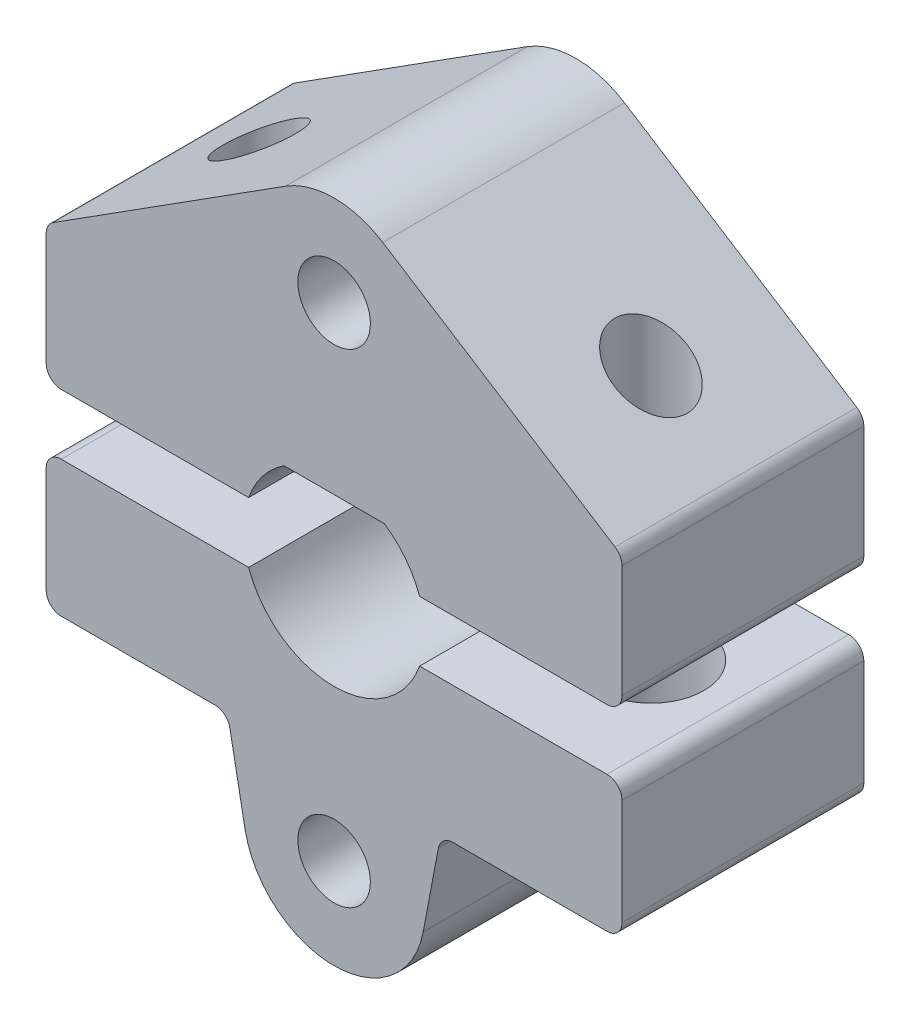
from build123d import *

# Parameters (mm, degrees)
SKETCH_1_R          = 1.2
EXTRUDE_1_DEPTH     = 8
EXTRUDE_1_2_DEPTH   = 8
SKETCH_2_R          = 1.2
CUT_EXTRUDE_1_DEPTH = 17.5
SKETCH_3_R          = 1.75
CUT_EXTRUDE_2_DEPTH = 4.5


with BuildPart() as part:
    # 草图1 → 凸台-拉伸1 (new body)
    with BuildSketch(Plane.XY):
        with BuildLine():
            Line((-1.658312395, 2.5), (1.658312395, 2.5))
            ThreePointArc((1.658312395, 2.5), (2.365419176, 1.84520788), (2.828427125, 1))
            Line((2.828427125, 1), (9.026279442, 1))
            ThreePointArc((9.026279442, 1), (9.379832832, 1.146446609), (9.526279442, 1.5))
            Line((9.526279442, 1.5), (9.526279442, 5.225344163))
            ThreePointArc((9.526279442, 5.225344163), (9.464514711, 5.466071912), (9.294480045, 5.647325722))
            Line((9.294480045, 5.647325722), (1.609203622, 10.531889354))
            ThreePointArc((1.609203622, 10.531889354), (0, 11), (-1.609203622, 10.531889354))
            Line((-1.609203622, 10.531889354), (-9.294480045, 5.647325722))
            ThreePointArc((-9.294480045, 5.647325722), (-9.464514711, 5.466071912), (-9.526279442, 5.225344163))
            Line((-9.526279442, 5.225344163), (-9.526279442, 1.5))
            ThreePointArc((-9.526279442, 1.5), (-9.379832832, 1.146446609), (-9.026279442, 1))
            Line((-9.026279442, 1), (-2.828427125, 1))
            ThreePointArc((-2.828427125, 1), (-2.365419176, 1.84520788), (-1.658312395, 2.5))
        make_face()
        with Locations((0, 8)):
            Circle(SKETCH_1_R, mode=Mode.SUBTRACT)
    extrude(amount=EXTRUDE_1_DEPTH)


with BuildPart() as body_2:
    # 草图1 → Extrude 1 2 (new body)
    with BuildSketch(Plane.XY):
        with BuildLine():
            Line((-9.026279442, -1), (-2.828427125, -1))
            ThreePointArc((-2.828427125, -1), (0, -3), (2.828427125, -1))
            Line((2.828427125, -1), (9.026279442, -1))
            ThreePointArc((9.026279442, -1), (9.379832832, -1.146446609), (9.526279442, -1.5))
            Line((9.526279442, -1.5), (9.526279442, -5))
            ThreePointArc((9.526279442, -5), (9.379832832, -5.353553391), (9.026279442, -5.5))
            Line((9.026279442, -5.5), (3.940542383, -5.5))
            ThreePointArc((3.940542383, -5.5), (3.621543848, -5.614980604), (3.449259891, -5.90704026))
            Line((3.449259891, -5.90704026), (2.94769495, -8.557758442))
            ThreePointArc((2.94769495, -8.557758442), (0, -11), (-2.94769495, -8.557758442))
            Line((-2.94769495, -8.557758442), (-3.449259891, -5.90704026))
            ThreePointArc((-3.449259891, -5.90704026), (-3.621543848, -5.614980604), (-3.940542383, -5.5))
            Line((-3.940542383, -5.5), (-9.026279442, -5.5))
            ThreePointArc((-9.026279442, -5.5), (-9.379832832, -5.353553391), (-9.526279442, -5))
            Line((-9.526279442, -5), (-9.526279442, -1.5))
            ThreePointArc((-9.526279442, -1.5), (-9.379832832, -1.146446609), (-9.026279442, -1))
        make_face()
        with Locations((0, -8)):
            Circle(SKETCH_1_R, mode=Mode.SUBTRACT)
    extrude(amount=EXTRUDE_1_2_DEPTH)


with BuildPart() as cut_extrude_1_tool:
    # 草图2 → 切除-拉伸1 (new body, through all)
    with BuildSketch(Plane.XZ.offset(5.5)):
        with Locations((6.483410912, 4)):
            Circle(SKETCH_2_R)
        with Locations((-6.483410912, 4)):
            Circle(SKETCH_2_R)
    extrude(amount=-CUT_EXTRUDE_1_DEPTH)


with BuildPart() as part_1:
    add(part.part)

    # 切除-拉伸1: cut by cut_extrude_1_tool
    add(cut_extrude_1_tool.part, mode=Mode.SUBTRACT)


with BuildPart() as body_2_1:
    add(body_2.part)

    # 切除-拉伸1: cut by cut_extrude_1_tool
    add(cut_extrude_1_tool.part, mode=Mode.SUBTRACT)

    # 草图3 → 切除-拉伸2 (cut)
    with BuildSketch(Plane.XZ.offset(5.5)):
        with Locations((-6.483410912, 4)):
            Circle(SKETCH_3_R)
        with Locations((6.483410912, 4)):
            Circle(SKETCH_3_R)
    extrude(amount=-CUT_EXTRUDE_2_DEPTH, mode=Mode.SUBTRACT)


solid = Compound([part_1.part, body_2_1.part])
